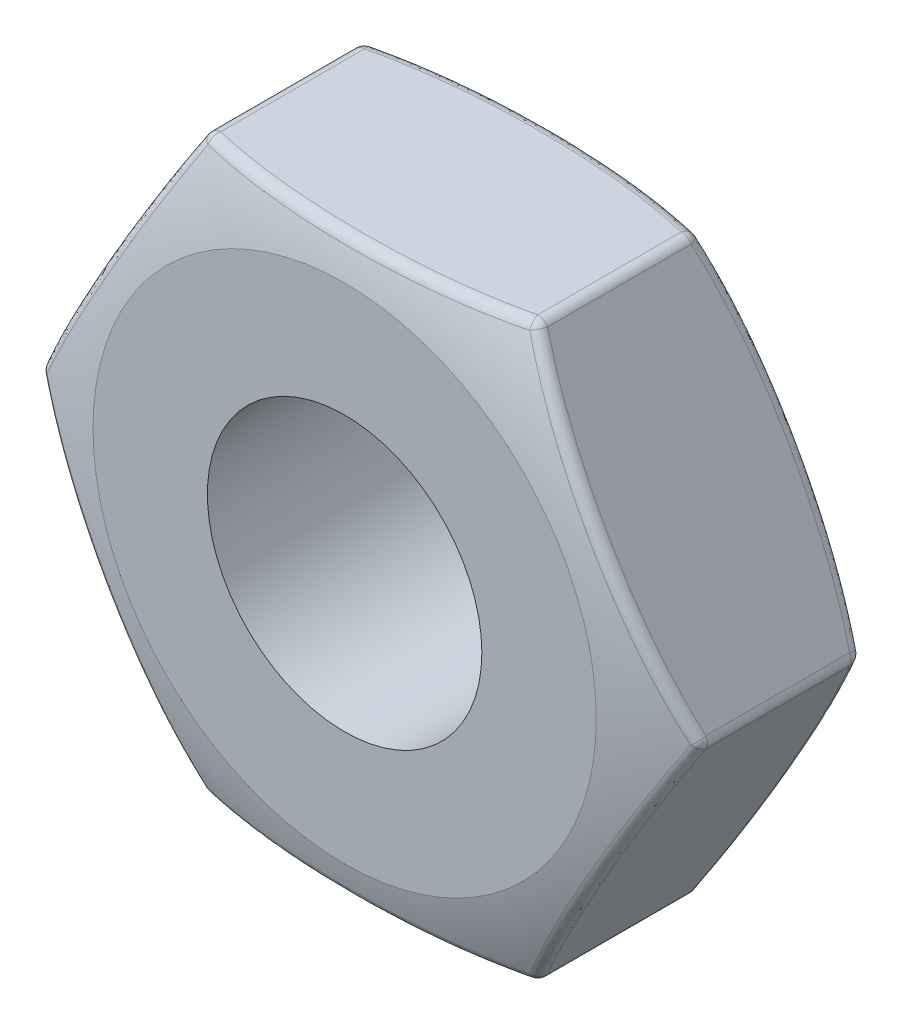
from build123d import *

# Parameters (mm, degrees)
EXTRUDE1_DEPTH     = 1.86
SKETCH3_R          = 1.2
CUT_EXTRUDE1_DEPTH = 12.5
FILLET1_R          = 0.1
FILLET2_R          = 0.1


with BuildPart() as part:
    # Sketch1 → Extrude1 (new body)
    with BuildSketch(Plane.XY):
        Polygon((2.886751346, 0), (1.443375673, 2.5), (-1.443375673, 2.5), (-2.886751346, 0), (-1.443375673, -2.5), (1.443375673, -2.5), align=None)
    extrude(amount=EXTRUDE1_DEPTH)

    # Sketch2 → Cut-Revolve1 (revolve, cut)
    with BuildSketch(Plane(origin=(0, 0, 0), x_dir=(0, 0, -1), z_dir=(1, 0, 0))):
        with BuildLine():
            Line((-0.5, 3.3), (0.473267316, 3.3))
            Line((0.473267316, 3.3), (0.473267316, 2.2))
            Line((0.473267316, 2.2), (0, 2.2))
            ThreePointArc((0, 2.2), (-0.194046192, 2.775433549), (-0.5, 3.3))
        make_face()
        with BuildLine():
            Line((-1.36, 3.3), (-2.836315201, 3.3))
            Line((-2.836315201, 3.3), (-2.836315201, 2.2))
            Line((-2.836315201, 2.2), (-1.86, 2.2))
            ThreePointArc((-1.86, 2.2), (-1.665953808, 2.775433549), (-1.36, 3.3))
        make_face()
    revolve(axis=Axis((0, 0, -1.011768521), (0, 0, 1)), mode=Mode.SUBTRACT)

    # Sketch3 → Cut-Extrude1 (cut)
    with BuildSketch(Plane.XY.offset(1.86)):
        Circle(SKETCH3_R)
    extrude(amount=-CUT_EXTRUDE1_DEPTH, mode=Mode.SUBTRACT)

    # Fillet1
    fillet1_edges = [part.edges().sort_by_distance(p)[0] for p in [
        (-1.443375673, 2.5, 0.93),
        (-2.886751346, 0, 0.93),
        (-1.443375673, -2.5, 0.93),
        (1.443375673, -2.5, 0.93),
        (2.886751346, 0, 0.93),
        (1.443375673, 2.5, 0.93),
    ]]
    fillet(fillet1_edges, radius=FILLET1_R)

    # Fillet2
    fillet2_edges = [part.edges().sort_by_distance(p)[0] for p in [
        (-2.165063509, 1.25, 1.775081788),
        (-2.165063509, 1.25, 0.084918212),
        (0, -2.2, 1.86),
        (-2.16506351, -1.25, 0.084918212),
        (0, -2.2, 1.86),
        (2.16506351, 1.25, 0.084918212),
        (2.165063509, -1.25, 0.084918212),
        (1.435640646, 2.48660254, 0.239676419),
        (2.871281292, 0, 0.239676419),
        (1.435640646, -2.48660254, 0.239676419),
        (-1.435640646, -2.48660254, 0.239676419),
        (-2.871281292, 0, 0.239676419),
        (-1.435640646, 2.48660254, 0.239676419),
        (0, -2.2, 0),
        (2.16506351, 1.25, 1.775081788),
        (-2.16506351, -1.25, 1.775081788),
        (0, -2.2, 0),
        (2.165063509, -1.25, 1.775081788),
        (1.435640646, 2.48660254, 1.620323581),
        (2.871281292, 0, 1.620323581),
        (1.435640646, -2.48660254, 1.620323581),
        (-1.435640646, -2.48660254, 1.620323581),
        (-2.871281292, 0, 1.620323581),
        (-1.435640646, 2.48660254, 1.620323581),
    ]]
    fillet(fillet2_edges, radius=FILLET2_R)


solid = part.part
